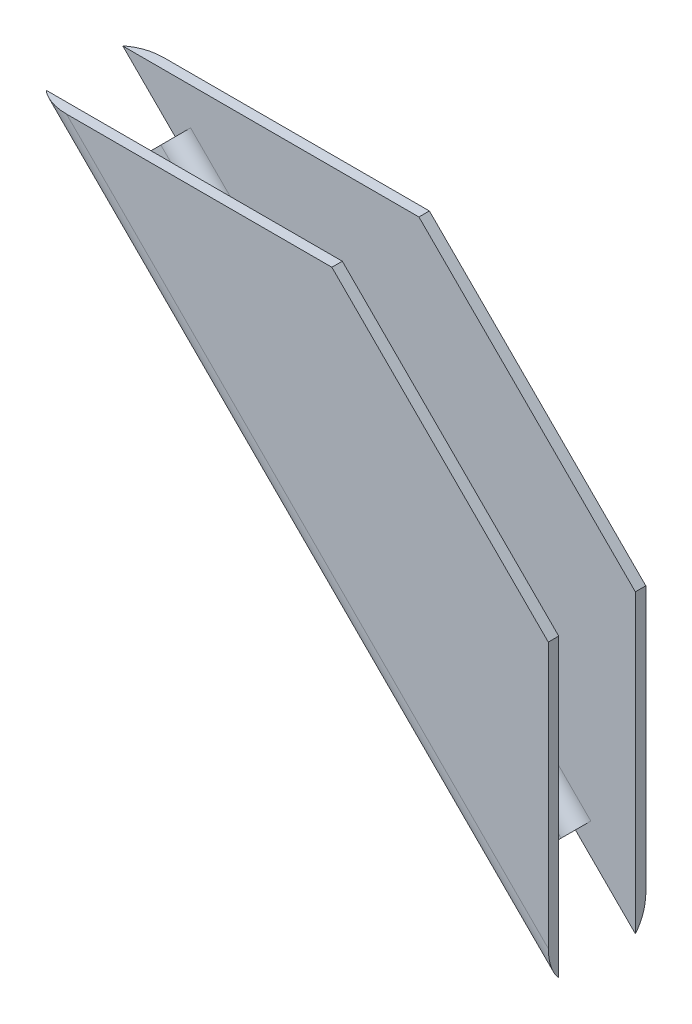
from build123d import *

# Parameters (mm, degrees)
BOSS_EXTRUDE1_START = 6.35
BOSS_EXTRUDE1_DEPTH = 0.762
BOSS_EXTRUDE2_DEPTH = 12.7
FILLET1_R           = 2.54
FILLET2_R           = 4.064


with BuildPart() as part:
    # Sketch4 → Boss-Extrude1 (new, symmetric)
    with BuildSketch(Plane.XY.offset(BOSS_EXTRUDE1_START)):
        Polygon((86.76732538935741, 78.2227633784087), (131.2173253893574, 78.2227633784087), (162.78478969827367, 46.65529906949232), (162.78478969827367, 2.205299069492165), align=None)
    boss_extrude1 = extrude(amount=BOSS_EXTRUDE1_DEPTH, both=True)

    # Sketch5 → Boss-Extrude2 (add)
    with BuildSketch(Plane(origin=(0, 0, 5.588), x_dir=(-1, 0, 0), z_dir=(0, 0, -1))):
        Polygon((-153.41145680361603, 11.578631964150068), (-95.03979201666652, 69.95029675109956), (-96.11742275119471, 71.02792748562776), (-154.48908753814433, 12.656262698678363), align=None)
    extrude(amount=BOSS_EXTRUDE2_DEPTH)

    # Mirror2: Boss-Extrude1 across plane
    add(boss_extrude1.mirror(Plane.XY))

    # Fillet1
    fillet1_edges = [part.edges().sort_by_distance(p)[0] for p in [
        (125.30325514466952, 41.84209509215306, 5.588),
        (125.30325514466952, 41.84209509215306, -5.587999999999999),
    ]]
    fillet(fillet1_edges, radius=FILLET1_R)

    # Fillet2
    fillet2_edges = [part.edges().sort_by_distance(p)[0] for p in [
        (124.77605754381554, 40.21403122395043, 7.112),
        (124.77605754381554, 40.214031223950435, -7.112),
    ]]
    fillet(fillet2_edges, radius=FILLET2_R)


solid = part.part
